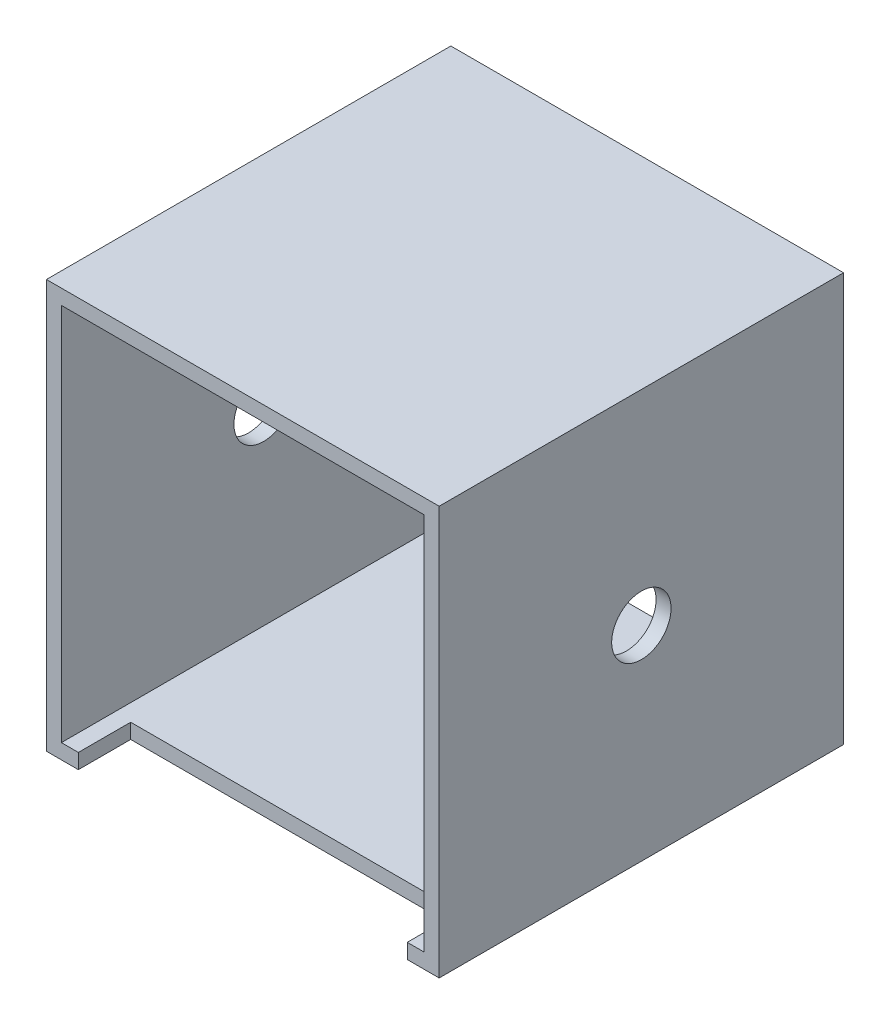
from build123d import *

# Parameters (mm, degrees)
SKETCH1_W               = 66.7258
SKETCH1_H               = 69.4182
SKETCH1_W_2             = 61.6458
SKETCH1_H_2             = 64.3382
EXTRUDE_THIN1_DEPTH     = 68.707
F_3_8_CLEARANCE_HOLE1_D = 10.0838
SKETCH4_W               = 55.88
SKETCH4_H               = 8.89
CUT_EXTRUDE1_DEPTH      = 3.54


with BuildPart() as part:
    # Sketch1 → Extrude-Thin1 (new body)
    with BuildSketch(Plane.XY):
        Rectangle(SKETCH1_W, SKETCH1_H)
        Rectangle(SKETCH1_W_2, SKETCH1_H_2, mode=Mode.SUBTRACT)
    extrude(amount=EXTRUDE_THIN1_DEPTH)

    # 3/8 Clearance Hole1 (through all)
    with Locations(Plane(origin=(33.3629, 0, 0), x_dir=(0, 0, -1), z_dir=(1, 0, 0))):
        with Locations((-34.3535, 0)):
            Hole(F_3_8_CLEARANCE_HOLE1_D / 2)

    # Sketch4 → Cut-Extrude1 (cut, through all)
    with BuildSketch(Plane(origin=(0, -32.1691, 0), x_dir=(1, 0, 0), z_dir=(0, 1, 0))):
        with Locations((0, -64.262)):
            Rectangle(SKETCH4_W, SKETCH4_H)
    extrude(amount=-CUT_EXTRUDE1_DEPTH, mode=Mode.SUBTRACT)


solid = part.part
